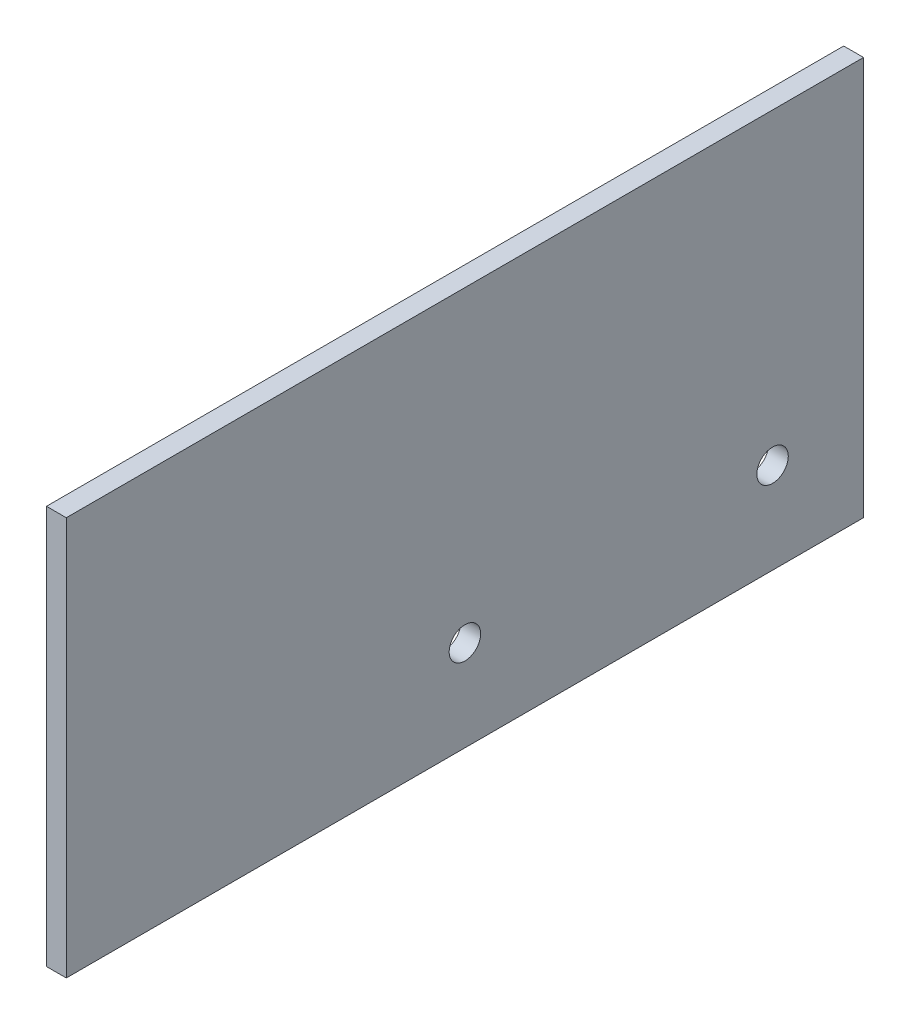
from build123d import *

# Parameters (mm, degrees)
SKETCH1_W               = 181
SKETCH1_H               = 90.5
BOSS_EXTRUDE1_DEPTH     = 2.25
SKETCH2_R               = 3.5687
CUT_EXTRUDE1_DEPTH      = 1
CUT_EXTRUDE1_DEPTH_BACK = 91.5


with BuildPart() as part:
    # Sketch1 → Boss-Extrude1 (new body, symmetric)
    with BuildSketch(Plane(origin=(0, 0, 0), x_dir=(0, 0, -1), z_dir=(1, 0, 0))):
        with Locations((0, -45.25)):
            Rectangle(SKETCH1_W, SKETCH1_H)
    extrude(amount=BOSS_EXTRUDE1_DEPTH, both=True)

    # Sketch2 → Cut-Extrude1 (cut, two sides)
    with BuildSketch(Plane(origin=(88.25, 0, 0), x_dir=(0, 0, -1), z_dir=(1, 0, 0))) as cut_extrude1_sk:
        with Locations((0, -69.85)):
            Circle(SKETCH2_R)
        with Locations((69.85, -69.85)):
            Circle(SKETCH2_R)
    extrude(amount=CUT_EXTRUDE1_DEPTH, mode=Mode.SUBTRACT)
    extrude(cut_extrude1_sk.sketch, amount=-CUT_EXTRUDE1_DEPTH_BACK, mode=Mode.SUBTRACT)


solid = part.part
